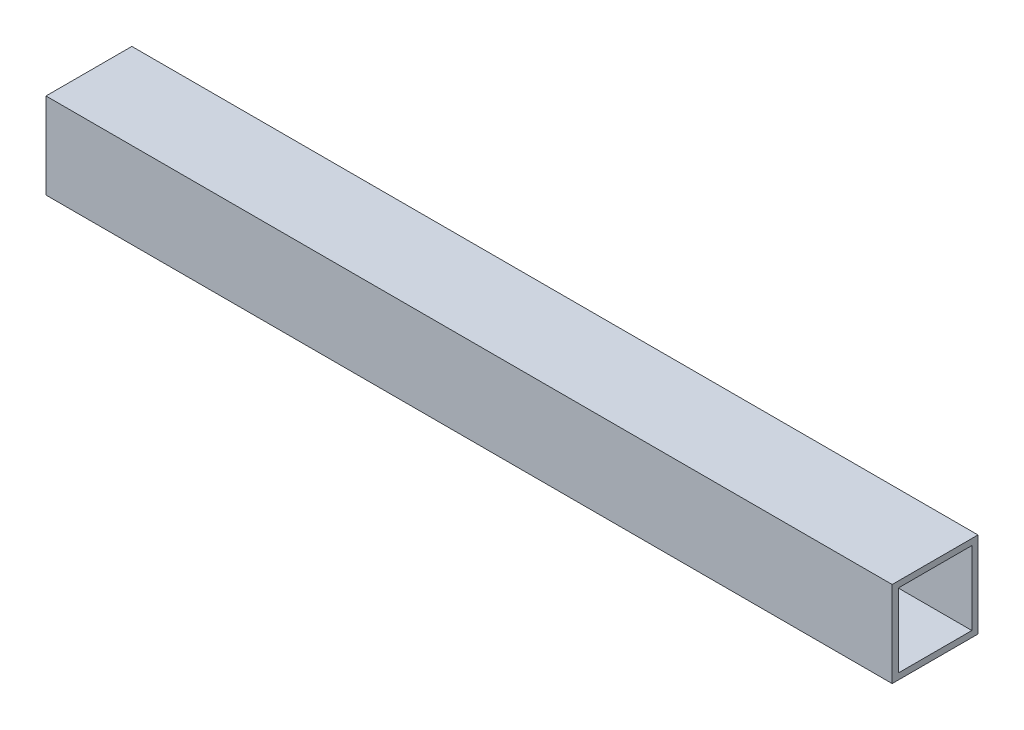
from build123d import *

# Parameters (mm, degrees)
SKETCH1_W           = 44.45
SKETCH1_H           = 44.45
SKETCH1_W_2         = 38.1
SKETCH1_H_2         = 38.1
BOSS_EXTRUDE1_DEPTH = 438.15


with BuildPart() as part:
    # Sketch1 → Boss-Extrude1 (new body)
    with BuildSketch(Plane(origin=(0, 0, 0), x_dir=(0, 0, -1), z_dir=(1, 0, 0))):
        with Locations((22.225, 22.225)):
            Rectangle(SKETCH1_W, SKETCH1_H)
        with Locations((22.225, 22.225)):
            Rectangle(SKETCH1_W_2, SKETCH1_H_2, mode=Mode.SUBTRACT)
    extrude(amount=BOSS_EXTRUDE1_DEPTH)


solid = part.part
